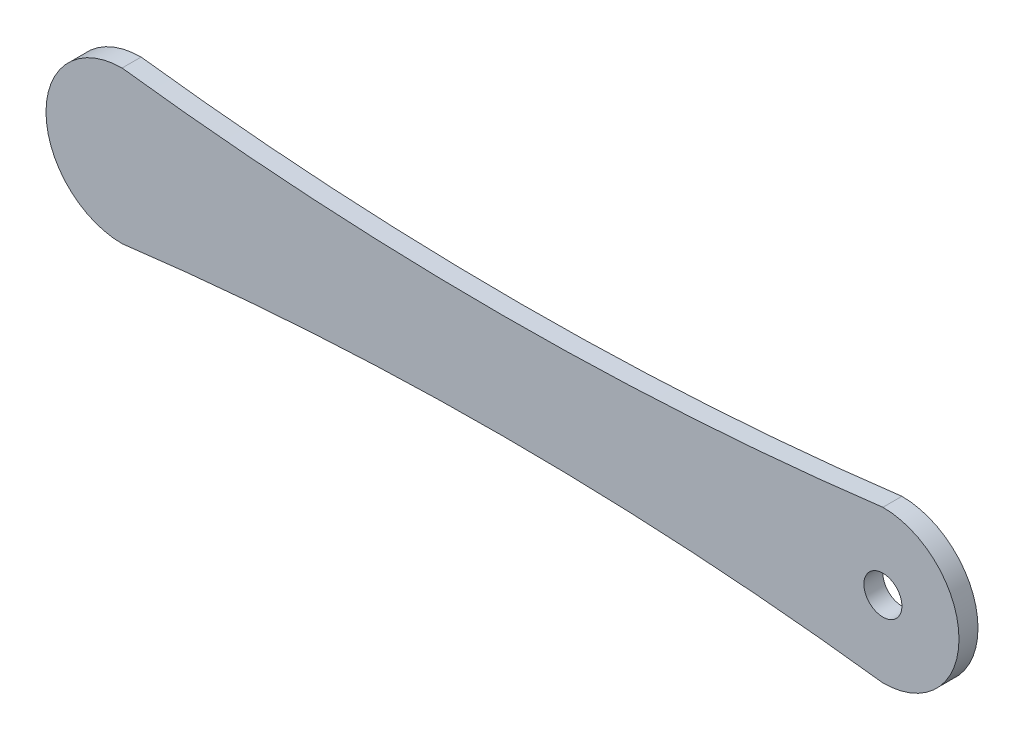
from build123d import *

# Parameters (mm, degrees)
BOSS_EXTRUDE1_DEPTH = 25
SKETCH2_R           = 50
BOSS_EXTRUDE2_DEPTH = 25
SKETCH3_R           = 25
CUT_EXTRUDE2_DEPTH  = 25


with BuildPart() as part:
    # Sketch1 → Boss-Extrude1 (new body)
    with BuildSketch(Plane.XY):
        with BuildLine():
            ThreePointArc((-500, 100), (-600, 0), (-500, -100))
            ThreePointArc((-500, -100), (0, -68.626966597), (500, -100))
            ThreePointArc((500, -100), (600, 0), (500, 100))
            ThreePointArc((500, 100), (0, 68.626966597), (-500, 100))
        make_face()
    extrude(amount=BOSS_EXTRUDE1_DEPTH)

    # Sketch2 → Boss-Extrude2 (add)
    with BuildSketch(Plane(origin=(0, 0, 0), x_dir=(1, 0, 0), z_dir=(0, 0, -1))):
        with Locations((-500, 0)):
            Circle(SKETCH2_R)
    extrude(amount=BOSS_EXTRUDE2_DEPTH)

    # Sketch3 → Cut-Extrude2 (cut)
    with BuildSketch(Plane.XY.offset(25)):
        with Locations((500, 0)):
            Circle(SKETCH3_R)
    extrude(amount=-CUT_EXTRUDE2_DEPTH, mode=Mode.SUBTRACT)


solid = part.part
